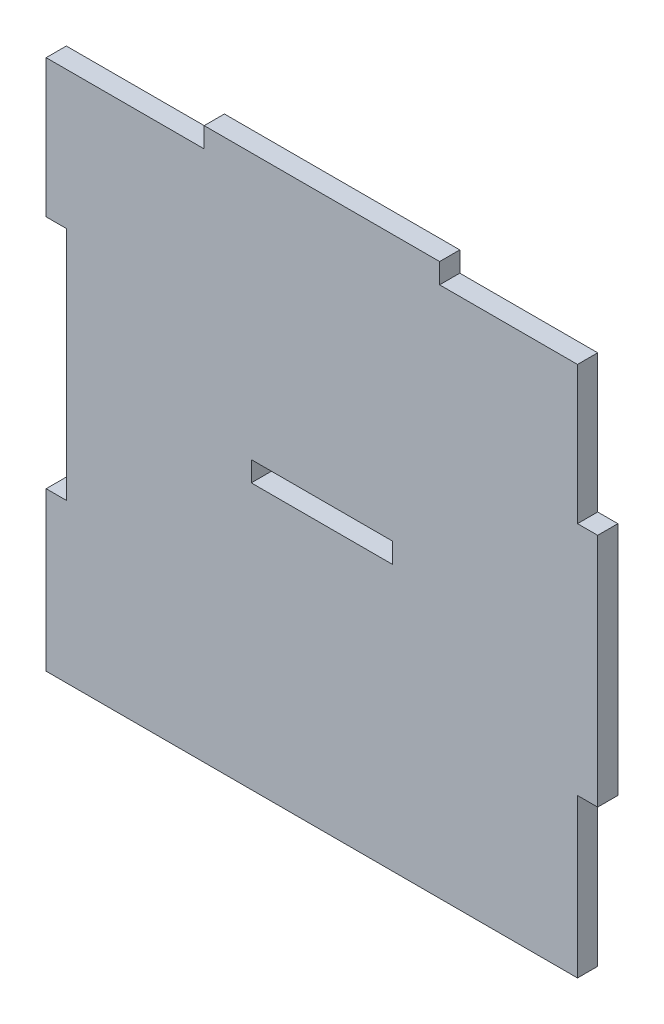
from build123d import *

# Parameters (mm, degrees)
BOSS_EXTRUDE1_DEPTH = 3
SKETCH2_W           = 21
SKETCH2_H           = 3
CUT_EXTRUDE1_DEPTH  = 3


with BuildPart() as part:
    # Sketch1 → Boss-Extrude1 (new body)
    with BuildSketch(Plane.XY):
        Polygon((-38, 39.5), (-17.5, 39.5), (-17.5, 42.5), (17.5, 42.5), (17.5, 39.5), (38, 39.5), (38, 19), (41, 19), (41, 16), (41, -16), (38, -16), (38, -19), (38, -39.5), (-41, -39.5), (-41, -19), (-41, -16), (-38, -16), (-38, 16), (-38, 19), (-41, 19), (-41, 39.5), align=None)
    extrude(amount=BOSS_EXTRUDE1_DEPTH)

    # Sketch2 → Cut-Extrude1 (cut)
    with BuildSketch(Plane.XY.offset(3)):
        with Locations((0, 1.5)):
            Rectangle(SKETCH2_W, SKETCH2_H)
    extrude(amount=-CUT_EXTRUDE1_DEPTH, mode=Mode.SUBTRACT)


solid = part.part
